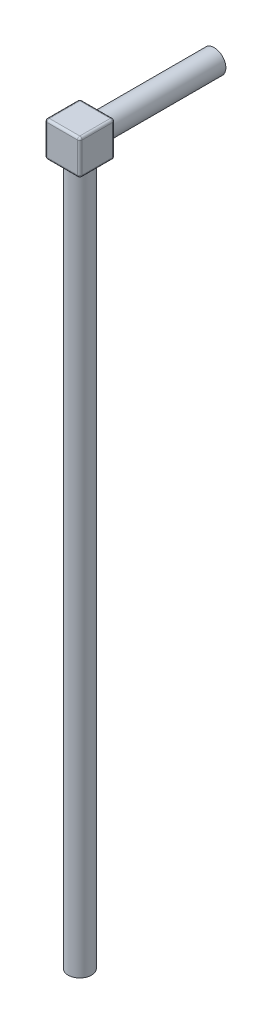
from build123d import *

# Parameters (mm, degrees)
SKETCH1_W           = 15
SKETCH1_H           = 15
BOSS_EXTRUDE1_DEPTH = 7.5
SKETCH2_R           = 5
BOSS_EXTRUDE2_DEPTH = 50
SKETCH3_R           = 5
BOSS_EXTRUDE3_DEPTH = 300
FILLET1_R           = 1


with BuildPart() as part:
    # Sketch1 → Boss-Extrude1 (new body, symmetric)
    with BuildSketch(Plane(origin=(0, 0, 0), x_dir=(1, 0, 0), z_dir=(0, 1, 0))):
        Rectangle(SKETCH1_W, SKETCH1_H)
    extrude(amount=BOSS_EXTRUDE1_DEPTH, both=True)

    # Sketch2 → Boss-Extrude2 (add)
    with BuildSketch(Plane(origin=(0, 0, -7.5), x_dir=(-1, 0, 0), z_dir=(0, 0, -1))):
        Circle(SKETCH2_R)
    extrude(amount=BOSS_EXTRUDE2_DEPTH)

    # Sketch3 → Boss-Extrude3 (add)
    with BuildSketch(Plane.XZ.offset(7.5)):
        Circle(SKETCH3_R)
    extrude(amount=BOSS_EXTRUDE3_DEPTH)

    # Fillet1
    fillet1_edges = [part.edges().sort_by_distance(p)[0] for p in [
        (-7.5, 7.5, 0),
        (0, 7.5, 7.5),
        (-5, -7.5, 0),
        (7.5, 7.5, 0),
        (0, -7.5, 7.5),
        (-7.5, -7.5, 0),
        (0, -7.5, -7.5),
        (7.5, -7.5, 0),
        (0, 7.5, -7.5),
        (7.5, 0, 7.5),
        (-7.5, 0, 7.5),
        (-7.5, 0, -7.5),
        (7.5, 0, -7.5),
    ]]
    fillet(fillet1_edges, radius=FILLET1_R)


solid = part.part
